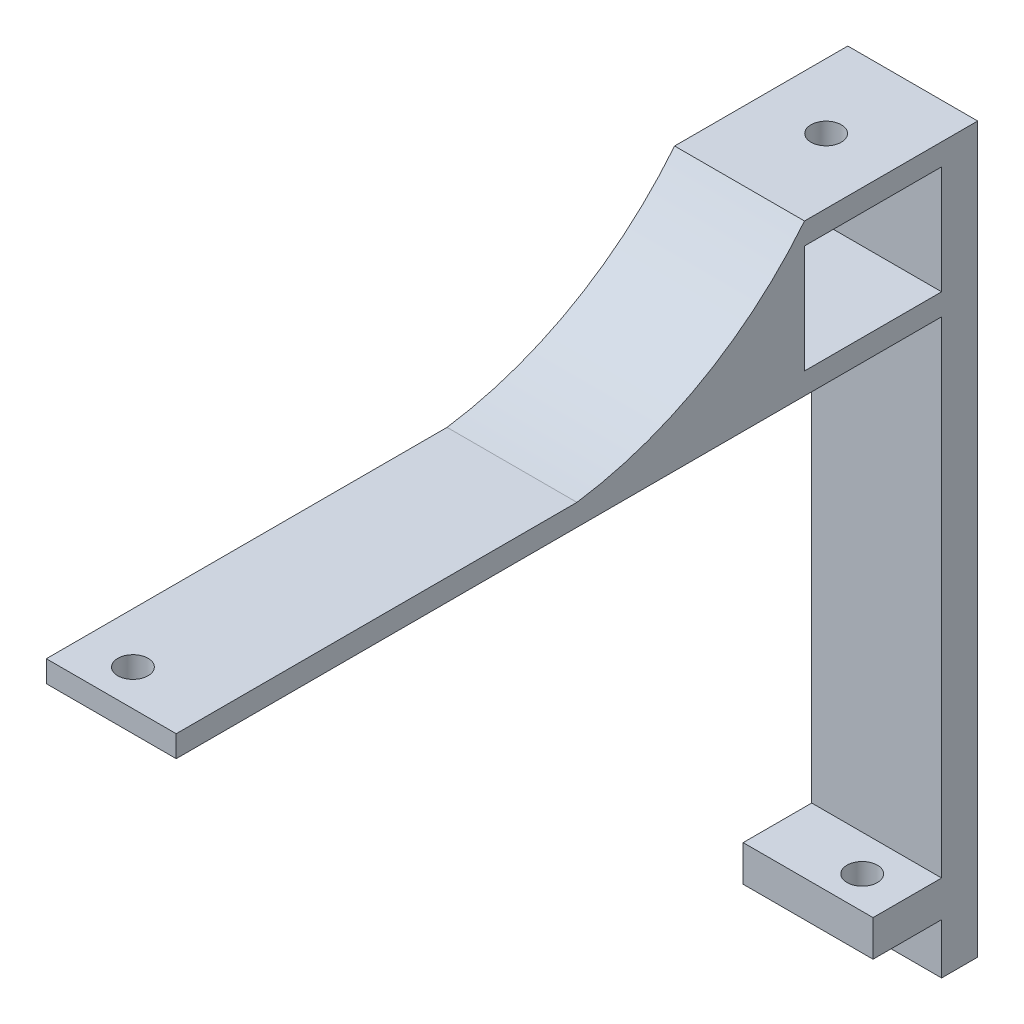
from build123d import *

# Parameters (mm, degrees)
SKETCH4_W           = 106.06440689
SKETCH4_H           = 3
SKETCH4_W_2         = 10
SKETCH4_H_2         = 5
BOSS_EXTRUDE1_DEPTH = 52
SKETCH5_R           = 2.1
CUT_EXTRUDE1_DEPTH  = 52
SKETCH6_R           = 2.1
CUT_EXTRUDE2_DEPTH  = 52
SKETCH7_W           = 16
SKETCH7_H           = 82.35034403
CUT_EXTRUDE4_DEPTH  = 124
BOSS_EXTRUDE2_DEPTH = 18
SKETCH9_R           = 2.1
CUT_EXTRUDE5_DEPTH  = 6
BOSS_EXTRUDE3_DEPTH = 18
SKETCH12_R          = 2.1
CUT_EXTRUDE7_DEPTH  = 11
SKETCH13_W          = 30.758926903
SKETCH13_H          = 118.81058029
CUT_EXTRUDE8_DEPTH  = 134
SKETCH14_W          = 18
SKETCH14_H          = 2
CUT_EXTRUDE9_DEPTH  = 10
BOSS_EXTRUDE4_START = -5
SKETCH15_W          = 18
SKETCH15_H          = 2
SKETCH15_R          = 2.1
BOSS_EXTRUDE4_DEPTH = 5
SKETCH16_R          = 2.1
CUT_EXTRUDE10_DEPTH = 68
SKETCH17_R          = 2.1
BOSS_EXTRUDE5_DEPTH = 3
SKETCH18_R          = 2.1
CUT_EXTRUDE11_DEPTH = 68
SKETCH19_W          = 18
SKETCH19_H          = 0.5
CUT_EXTRUDE12_DEPTH = 68
SKETCH20_W          = 7.887405645
SKETCH20_H          = 8
BOSS_EXTRUDE6_DEPTH = 5
SKETCH21_R          = 2.1
CUT_EXTRUDE13_DEPTH = 10


with BuildPart() as part:
    # Sketch4 → Boss-Extrude1 (new body)
    with BuildSketch(Plane(origin=(0, 0, 0), x_dir=(0, 0, -1), z_dir=(1, 0, 0))):
        with Locations((-20.39261819, 190.914352888)):
            Rectangle(SKETCH4_W, SKETCH4_H)
        Polygon((32.639585255, 189.414352888), (32.639585255, 122.064008858), (32.639585255, 117.064008858), (32.639585255, 110.064008858), (37.639585255, 110.064008858), (37.639585255, 192.414352888), (32.639585255, 192.414352888), align=None)
        with Locations((27.639585255, 119.564008858)):
            Rectangle(SKETCH4_W_2, SKETCH4_H_2)
    extrude(amount=BOSS_EXTRUDE1_DEPTH)

    # Sketch5 → Cut-Extrude1 (cut)
    with BuildSketch(Plane(origin=(0, 122.064008858, 0), x_dir=(1, 0, 0), z_dir=(0, 1, 0))):
        with Locations((6, 27.049585255)):
            Circle(SKETCH5_R)
        with Locations((46, 27.639585255)):
            Circle(SKETCH5_R)
    extrude(amount=-CUT_EXTRUDE1_DEPTH, mode=Mode.SUBTRACT)

    # Sketch6 → Cut-Extrude2 (cut)
    with BuildSketch(Plane(origin=(0, 192.414352888, 0), x_dir=(1, 0, 0), z_dir=(0, 1, 0))):
        with Locations((41, -68.424821635)):
            Circle(SKETCH6_R)
        with Locations((11, -68.424821635)):
            Circle(SKETCH6_R)
    extrude(amount=-CUT_EXTRUDE2_DEPTH, mode=Mode.SUBTRACT)

    # Sketch7 → Cut-Extrude4 (cut)
    with BuildSketch(Plane(origin=(0, 0, -37.639585255), x_dir=(-1, 0, 0), z_dir=(0, 0, -1))):
        with Locations((-26, 151.239180873)):
            Rectangle(SKETCH7_W, SKETCH7_H)
    extrude(amount=-CUT_EXTRUDE4_DEPTH, mode=Mode.SUBTRACT)

    # Sketch8 → Boss-Extrude2 (add)
    with BuildSketch(Plane.ZY):
        with BuildLine():
            Line((-37.639585255, 210.414352888), (-37.639585255, 192.414352888))
            Line((-37.639585255, 192.414352888), (-32.639585255, 192.414352888))
            Line((-32.639585255, 192.414352888), (-32.639585255, 207.414352888))
            Line((-32.639585255, 207.414352888), (-13.639585255, 207.414352888))
            Line((-13.639585255, 207.414352888), (-13.639585255, 192.414352888))
            Line((-13.639585255, 192.414352888), (17.89261819, 192.414352888))
            ThreePointArc((17.89261819, 192.414352888), (0.423706042, 198.431388178), (-13.639585255, 210.414352888))
            Line((-13.639585255, 210.414352888), (-37.639585255, 210.414352888))
        make_face()
    extrude(amount=-BOSS_EXTRUDE2_DEPTH)

    # Sketch9 → Cut-Extrude5 (cut)
    with BuildSketch(Plane(origin=(0, 210.414352888, 0), x_dir=(1, 0, 0), z_dir=(0, 1, 0))):
        with Locations((9, 25.639585255)):
            Circle(SKETCH9_R)
    extrude(amount=-CUT_EXTRUDE5_DEPTH, mode=Mode.SUBTRACT)

    # Sketch11 → Boss-Extrude3 (add)
    with BuildSketch(Plane(origin=(52, 0, 0), x_dir=(0, 0, -1), z_dir=(1, 0, 0))):
        with BuildLine():
            Line((32.639585255, 192.414352888), (37.639585255, 192.414352888))
            Line((37.639585255, 192.414352888), (37.639585255, 210.414352888))
            Line((37.639585255, 210.414352888), (13.639585255, 210.414352888))
            ThreePointArc((13.639585255, 210.414352888), (-0.423706042, 198.431388178), (-17.89261819, 192.414352888))
            Line((-17.89261819, 192.414352888), (13.639585255, 192.414352888))
            Line((13.639585255, 192.414352888), (13.639585255, 207.414352888))
            Line((13.639585255, 207.414352888), (32.639585255, 207.414352888))
            Line((32.639585255, 207.414352888), (32.639585255, 192.414352888))
        make_face()
    extrude(amount=-BOSS_EXTRUDE3_DEPTH)

    # Sketch12 → Cut-Extrude7 (cut)
    with BuildSketch(Plane(origin=(0, 210.414352888, 0), x_dir=(1, 0, 0), z_dir=(0, 1, 0))):
        with Locations((43, 25.639585255)):
            Circle(SKETCH12_R)
    extrude(amount=-CUT_EXTRUDE7_DEPTH, mode=Mode.SUBTRACT)

    # Sketch13 → Cut-Extrude8 (cut)
    with BuildSketch(Plane(origin=(0, 210.414352888, 0), x_dir=(1, 0, 0), z_dir=(0, 1, 0))):
        with Locations((9.143188102, -17.675085242)):
            Rectangle(SKETCH13_W, SKETCH13_H)
    extrude(amount=-CUT_EXTRUDE8_DEPTH, mode=Mode.SUBTRACT)

    # Sketch14 → Cut-Extrude9 (cut)
    with BuildSketch(Plane(origin=(0, 122.064008858, 0), x_dir=(1, 0, 0), z_dir=(0, 1, 0))):
        with Locations((43, 23.639585255)):
            Rectangle(SKETCH14_W, SKETCH14_H)
    extrude(amount=-CUT_EXTRUDE9_DEPTH, mode=Mode.SUBTRACT)

    # Sketch15 → Boss-Extrude4 (add)
    with BuildSketch(Plane(origin=(0, 122.064008858, 0), x_dir=(1, 0, 0), z_dir=(0, 1, 0)).offset(BOSS_EXTRUDE4_START)):
        with Locations((43, 23.639585255)):
            Rectangle(SKETCH15_W, SKETCH15_H)
        with Locations((46, 27.639585255)):
            Circle(SKETCH15_R)
    extrude(amount=BOSS_EXTRUDE4_DEPTH)

    # Sketch16 → Cut-Extrude10 (cut)
    with BuildSketch(Plane(origin=(0, 122.064008858, 0), x_dir=(1, 0, 0), z_dir=(0, 1, 0))):
        with Locations((46, 27.639585255)):
            Circle(SKETCH16_R)
    extrude(amount=-CUT_EXTRUDE10_DEPTH, mode=Mode.SUBTRACT)

    # Sketch17 → Boss-Extrude5 (add)
    with BuildSketch(Plane(origin=(0, 192.414352888, 0), x_dir=(1, 0, 0), z_dir=(0, 1, 0))):
        with Locations((41, -68.424821635)):
            Circle(SKETCH17_R)
    extrude(amount=-BOSS_EXTRUDE5_DEPTH)

    # Sketch18 → Cut-Extrude11 (cut)
    with BuildSketch(Plane(origin=(0, 192.414352888, 0), x_dir=(1, 0, 0), z_dir=(0, 1, 0))):
        with Locations((41, -68.424821635)):
            Circle(SKETCH18_R)
    extrude(amount=-CUT_EXTRUDE11_DEPTH, mode=Mode.SUBTRACT)

    # Sketch19 → Cut-Extrude12 (cut)
    with BuildSketch(Plane(origin=(0, 122.064008858, 0), x_dir=(1, 0, 0), z_dir=(0, 1, 0))):
        with Locations((43, 22.889585255)):
            Rectangle(SKETCH19_W, SKETCH19_H)
    extrude(amount=-CUT_EXTRUDE12_DEPTH, mode=Mode.SUBTRACT)

    # Sketch20 → Boss-Extrude6 (add)
    with BuildSketch(Plane(origin=(0, 122.064008858, 0), x_dir=(1, 0, 0), z_dir=(0, 1, 0))):
        with Locations((45.93127306, 28.865937897)):
            Rectangle(SKETCH20_W, SKETCH20_H)
    extrude(amount=-BOSS_EXTRUDE6_DEPTH)

    # Sketch21 → Cut-Extrude13 (cut)
    with BuildSketch(Plane(origin=(0, 122.064008858, 0), x_dir=(1, 0, 0), z_dir=(0, 1, 0))):
        with Locations((46, 27.639585255)):
            Circle(SKETCH21_R)
    extrude(amount=-CUT_EXTRUDE13_DEPTH, mode=Mode.SUBTRACT)


solid = part.part
